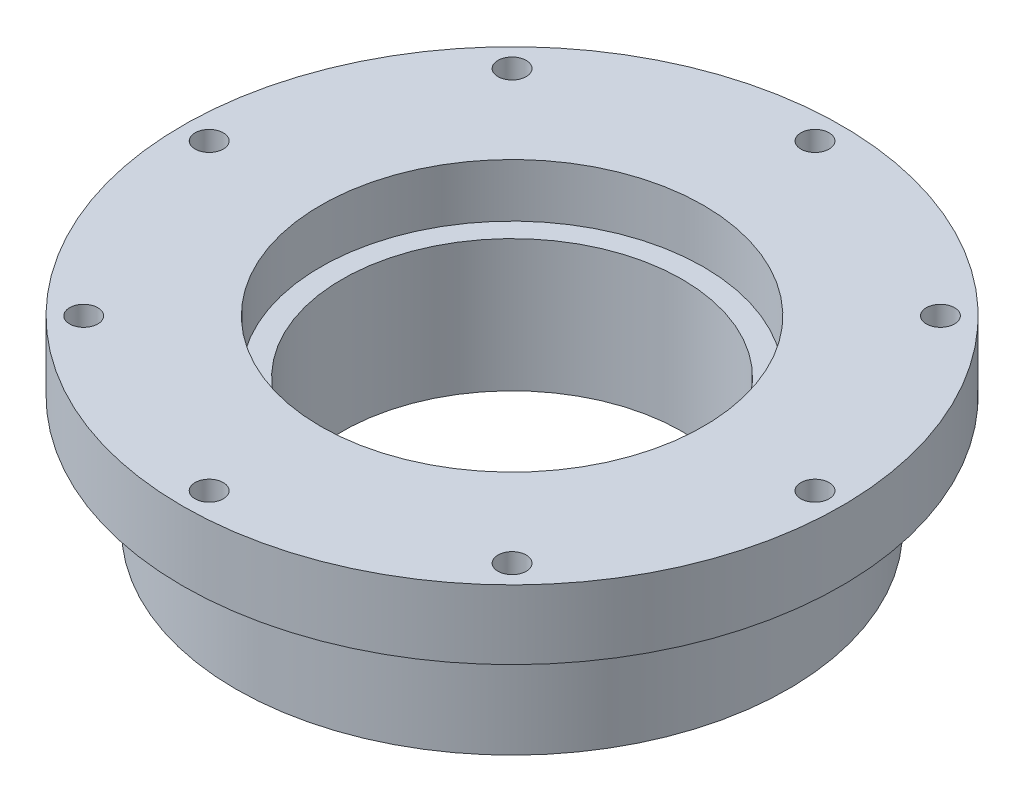
from build123d import *

# Parameters (mm, degrees)
SKETCH1_R           = 55.88
BOSS_EXTRUDE1_DEPTH = 23.495
SKETCH2_R           = 66.675
BOSS_EXTRUDE2_DEPTH = 13.97
FILLET1_R           = 7.62
SKETCH3_R           = 2.8575
CUT_EXTRUDE1_DEPTH  = 38.465
CIRPATTERN1_COUNT   = 8
SKETCH4_R           = 38.735
CUT_EXTRUDE2_DEPTH  = 10.795
SKETCH5_R           = 34.4043
CUT_EXTRUDE3_DEPTH  = 40.894


with BuildPart() as part:
    # Sketch1 → Boss-Extrude1 (new body)
    with BuildSketch(Plane(origin=(0, 0, 0), x_dir=(1, 0, 0), z_dir=(0, 1, 0))):
        Circle(SKETCH1_R)
    extrude(amount=BOSS_EXTRUDE1_DEPTH)

    # Sketch2 → Boss-Extrude2 (add)
    with BuildSketch(Plane(origin=(0, 23.495, 0), x_dir=(1, 0, 0), z_dir=(0, 1, 0))):
        Circle(SKETCH2_R)
    extrude(amount=BOSS_EXTRUDE2_DEPTH)

    # Fillet1
    fillet1_edges = [part.edges().sort_by_distance(p)[0] for p in [
        (-55.88, 23.495, 0),
    ]]
    fillet(fillet1_edges, radius=FILLET1_R)

    # Sketch3 → Cut-Extrude1 (cut, through all)
    with BuildSketch(Plane(origin=(0, 37.465, 0), x_dir=(1, 0, 0), z_dir=(0, 1, 0))):
        with Locations((0, 61.2775)):
            Circle(SKETCH3_R)
    cut_extrude1 = extrude(amount=-CUT_EXTRUDE1_DEPTH, mode=Mode.SUBTRACT)

    # CirPattern1: Cut-Extrude1 ×8 about axis
    cirpattern1_axis = Axis((0, 0, 0), (0, 1, 0))
    for i in range(1, CIRPATTERN1_COUNT):
        add(cut_extrude1.rotate(cirpattern1_axis, i * 360 / CIRPATTERN1_COUNT), mode=Mode.SUBTRACT)

    # Sketch4 → Cut-Extrude2 (cut)
    with BuildSketch(Plane(origin=(0, 37.465, 0), x_dir=(1, 0, 0), z_dir=(0, 1, 0))):
        Circle(SKETCH4_R)
    extrude(amount=-CUT_EXTRUDE2_DEPTH, mode=Mode.SUBTRACT)

    # Sketch5 → Cut-Extrude3 (cut)
    with BuildSketch(Plane(origin=(0, 26.67, 0), x_dir=(1, 0, 0), z_dir=(0, 1, 0))):
        Circle(SKETCH5_R)
    extrude(amount=-CUT_EXTRUDE3_DEPTH, mode=Mode.SUBTRACT)


solid = part.part
